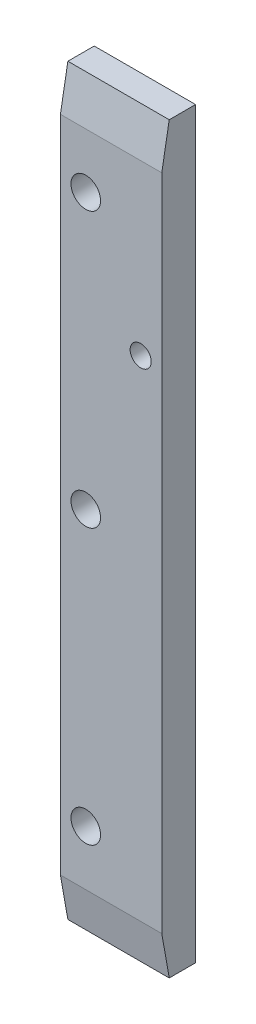
from build123d import *

# Parameters (mm, degrees)
SKETCH_1_R             = 1.75
EXTRUDE_1_DEPTH        = 4
HOLE_WIZARD_M3_1_D     = 2.5
HOLE_WIZARD_M3_1_DEPTH = 9.5
HOLE_WIZARD_M3_1_TIP   = 0.751075774
CHAMFER_1_SIZE         = 5
CHAMFER_1_SIZE2        = 0.881634904
CHAMFER_2_SIZE         = 5
CHAMFER_2_SIZE2        = 0.881634904


with BuildPart() as part:
    # 草图1 → 凸台-拉伸1 (new body)
    with BuildSketch(Plane.XY):
        Polygon((-12, 0), (0, 0), (0, -5), (0, -83), (0, -88), (-12, -88), (-12, -83), (-12, -5), align=None)
        with Locations((-9, -76.5)):
            Circle(SKETCH_1_R, mode=Mode.SUBTRACT)
        with Locations((-9, -44)):
            Circle(SKETCH_1_R, mode=Mode.SUBTRACT)
        with Locations((-9, -11.5)):
            Circle(SKETCH_1_R, mode=Mode.SUBTRACT)
    extrude(amount=EXTRUDE_1_DEPTH)

    # M3 螺纹孔1
    with Locations(Plane.XY.offset(4)):
        with Locations((-2.5, -25)):
            Hole(HOLE_WIZARD_M3_1_D / 2, depth=HOLE_WIZARD_M3_1_DEPTH)
            with Locations((0, 0, -(HOLE_WIZARD_M3_1_DEPTH + HOLE_WIZARD_M3_1_TIP / 2))):  # 118° drill point
                Cone(0, HOLE_WIZARD_M3_1_D / 2, HOLE_WIZARD_M3_1_TIP, mode=Mode.SUBTRACT)

    # 倒角1
    chamfer_1_edges = [part.edges().sort_by_distance(p)[0] for p in [
        (-6, -88, 4),
    ]]
    chamfer_1_side = [part.faces().sort_by_distance(p)[0] for p in [
        (-5.932099717, -44.091238005, 4),
    ]]
    chamfer(chamfer_1_edges, length=CHAMFER_1_SIZE, length2=CHAMFER_1_SIZE2, reference=chamfer_1_side[0])

    # 倒角2
    chamfer_2_edges = [part.edges().sort_by_distance(p)[0] for p in [
        (-6, 0, 4),
    ]]
    chamfer_2_side = [part.faces().sort_by_distance(p)[0] for p in [
        (-5.927865775, -41.509182575, 4),
    ]]
    chamfer(chamfer_2_edges, length=CHAMFER_2_SIZE, length2=CHAMFER_2_SIZE2, reference=chamfer_2_side[0])


solid = part.part
